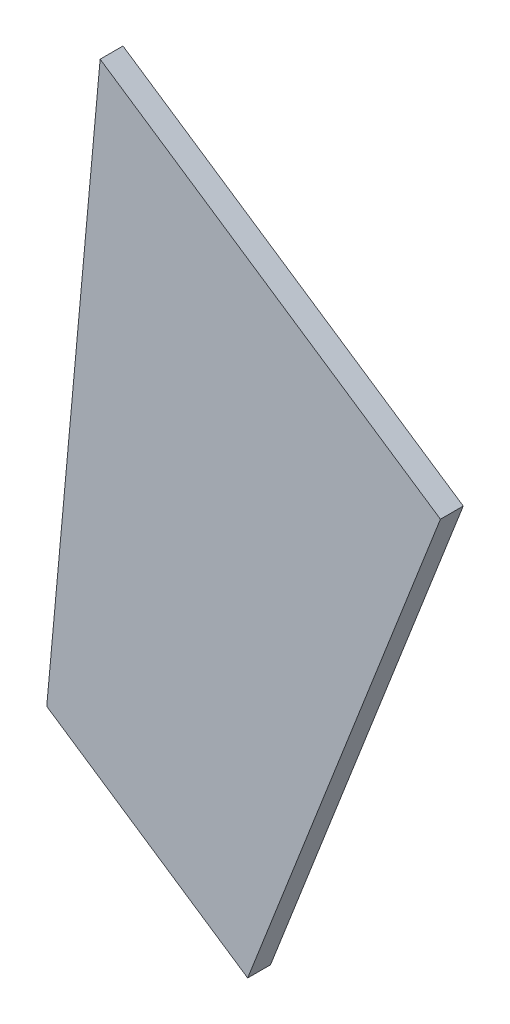
from build123d import *

# Parameters (mm, degrees)
BOSS_EXTRUDE1_DEPTH = 3


with BuildPart() as part:
    # Sketch1 → Boss-Extrude1 (new body)
    with BuildSketch(Plane.XY):
        Polygon((-7.018732355, -77.173394303), (0, 0), (44.723822302, -30), (19.389475765, -94.88758336), align=None)
    extrude(amount=BOSS_EXTRUDE1_DEPTH)


solid = part.part
